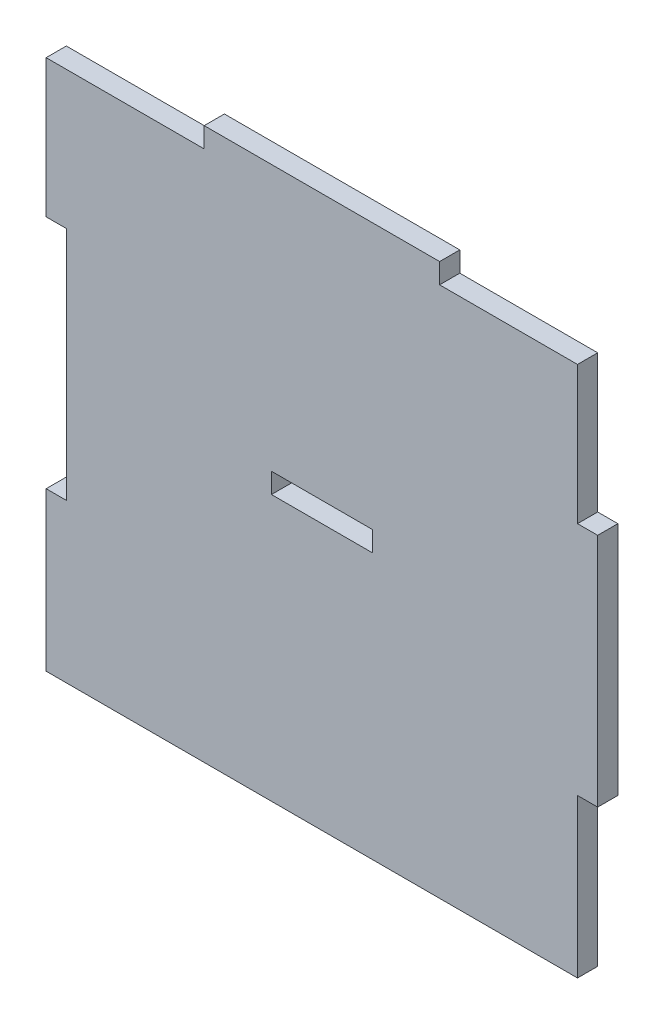
from build123d import *

# Parameters (mm, degrees)
BOSS_EXTRUDE1_DEPTH = 3
SKETCH2_W           = 15
SKETCH2_H           = 3
CUT_EXTRUDE1_DEPTH  = 3


with BuildPart() as part:
    # Sketch1 → Boss-Extrude1 (new body)
    with BuildSketch(Plane.XY):
        Polygon((-38, 39.5), (-17.5, 39.5), (-17.5, 42.5), (17.5, 42.5), (17.5, 39.5), (38, 39.5), (38, 19), (41, 19), (41, 16), (41, -16), (38, -16), (38, -19), (38, -39.5), (-41, -39.5), (-41, -19), (-41, -16), (-38, -16), (-38, 16), (-38, 19), (-41, 19), (-41, 39.5), align=None)
    extrude(amount=BOSS_EXTRUDE1_DEPTH)

    # Sketch2 → Cut-Extrude1 (cut)
    with BuildSketch(Plane.XY.offset(3)):
        with Locations((0, 1.5)):
            Rectangle(SKETCH2_W, SKETCH2_H)
    extrude(amount=-CUT_EXTRUDE1_DEPTH, mode=Mode.SUBTRACT)


solid = part.part
